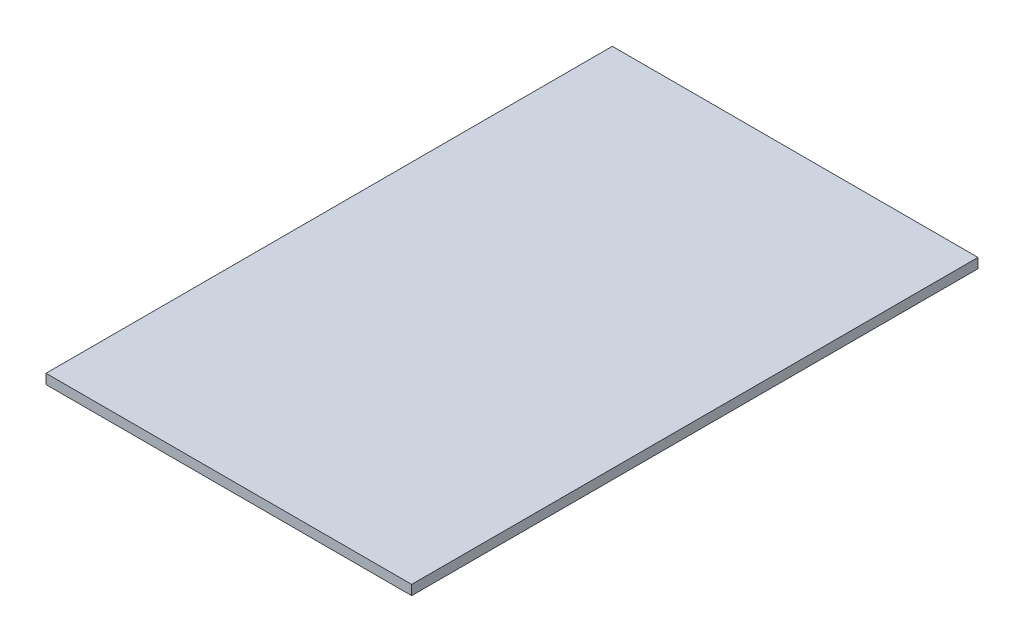
from build123d import *

# Parameters (mm, degrees)
SKETCH1_W           = 41
SKETCH1_H           = 63.5
BOSS_EXTRUDE1_DEPTH = 1.1


with BuildPart() as part:
    # Sketch1 → Boss-Extrude1 (new body)
    with BuildSketch(Plane(origin=(0, 0, 0), x_dir=(1, 0, 0), z_dir=(0, 1, 0))):
        Rectangle(SKETCH1_W, SKETCH1_H)
    extrude(amount=BOSS_EXTRUDE1_DEPTH)


solid = part.part
